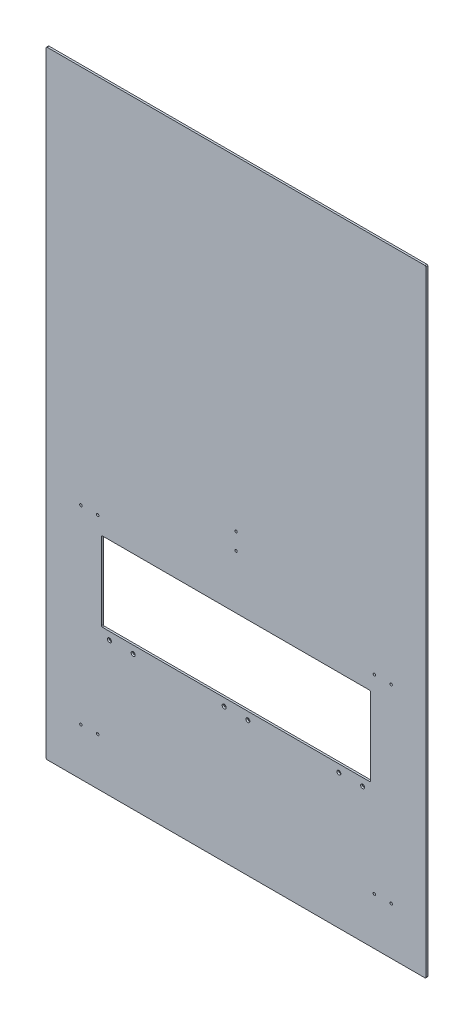
from build123d import *

# Parameters (mm, degrees)
SKETCH1_W                                     = 1219.2
SKETCH1_H                                     = 1981.2
SKETCH1_W_2                                   = 863.6
SKETCH1_H_2                                   = 254
BOSS_EXTRUDE1_DEPTH                           = 6.35
CSK_FOR_1_4_FLAT_HEAD_MACHINE_SCREW1_AT_COUNT = 2
CSK_FOR_1_4_FLAT_HEAD_MACHINE_SCREW1_AT_PITCH = 76.2
CSK_FOR_1_4_FLAT_HEAD_MACHINE_SCREW1_2_COUNT  = 2
CSK_FOR_1_4_FLAT_HEAD_MACHINE_SCREW1_2_PITCH  = 736.600036601
CSK_FOR_1_4_FLAT_HEAD_MACHINE_SCREW1_3_COUNT  = 2
CSK_FOR_1_4_FLAT_HEAD_MACHINE_SCREW1_3_PITCH  = 812.800033169
CSK_FOR_1_4_FLAT_HEAD_MACHINE_SCREW1_4_COUNT  = 2
CSK_FOR_1_4_FLAT_HEAD_MACHINE_SCREW1_4_PITCH  = 368.300013149
CSK_FOR_1_4_FLAT_HEAD_MACHINE_SCREW1_5_COUNT  = 2
CSK_FOR_1_4_FLAT_HEAD_MACHINE_SCREW1_5_PITCH  = 444.500010895
FILLET1_R                                     = 3.175
F_5_16_0_3125_DIAMETER_HOLE2_D                = 7.9375


with BuildPart() as part:
    # Sketch1 → Boss-Extrude1 (new body)
    with BuildSketch(Plane.XY):
        with Locations((609.6, 990.6)):
            Rectangle(SKETCH1_W, SKETCH1_H)
        with Locations((609.6, 584.2)):
            Rectangle(SKETCH1_W_2, SKETCH1_H_2, mode=Mode.SUBTRACT)
    extrude(amount=BOSS_EXTRUDE1_DEPTH)

    # Sketch3 → CSK for 1/4 Flat Head Machine Screw1 (revolve, cut)
    with BuildSketch(Plane(origin=(203.2, 432.304928843, 6.35), x_dir=(0, -1, 0), z_dir=(1, 0, 0))):
        Polygon((0, 0), (0, 6.35), (3.57124, 6.35), (3.57124, 3.298865467), (6.4389, 0), align=None)
    csk_for_1_4_flat_head_machine_screw1 = revolve(axis=Axis((203.2, 432.304928843, 12.7), (0, 0, -1)), mode=Mode.SUBTRACT)

    # CSK for 1/4 Flat Head Machine Screw1 at: CSK for 1/4 Flat Head Machine Screw1 ×2
    with Locations(*[(i * CSK_FOR_1_4_FLAT_HEAD_MACHINE_SCREW1_AT_PITCH, 0, 0) for i in range(1, CSK_FOR_1_4_FLAT_HEAD_MACHINE_SCREW1_AT_COUNT)]):
        add(csk_for_1_4_flat_head_machine_screw1, mode=Mode.SUBTRACT)

    # CSK for 1_4 Flat Head Machine Screw1 2: CSK for 1/4 Flat Head Machine Screw1 ×2
    with Locations(*[Vector(0.99999995, 0.000315241, 0) * (i * CSK_FOR_1_4_FLAT_HEAD_MACHINE_SCREW1_2_PITCH) for i in range(1, CSK_FOR_1_4_FLAT_HEAD_MACHINE_SCREW1_2_COUNT)]):
        add(csk_for_1_4_flat_head_machine_screw1, mode=Mode.SUBTRACT)

    # CSK for 1_4 Flat Head Machine Screw1 3: CSK for 1/4 Flat Head Machine Screw1 ×2
    with Locations(*[Vector(0.999999959, 0.000285687, 0) * (i * CSK_FOR_1_4_FLAT_HEAD_MACHINE_SCREW1_3_PITCH) for i in range(1, CSK_FOR_1_4_FLAT_HEAD_MACHINE_SCREW1_3_COUNT)]):
        add(csk_for_1_4_flat_head_machine_screw1, mode=Mode.SUBTRACT)

    # CSK for 1_4 Flat Head Machine Screw1 4: CSK for 1/4 Flat Head Machine Screw1 ×2
    with Locations(*[Vector(0.999999964, 0.000267211, 0) * (i * CSK_FOR_1_4_FLAT_HEAD_MACHINE_SCREW1_4_PITCH) for i in range(1, CSK_FOR_1_4_FLAT_HEAD_MACHINE_SCREW1_4_COUNT)]):
        add(csk_for_1_4_flat_head_machine_screw1, mode=Mode.SUBTRACT)

    # CSK for 1_4 Flat Head Machine Screw1 5: CSK for 1/4 Flat Head Machine Screw1 ×2
    with Locations(*[Vector(0.999999975, 0.000221404, 0) * (i * CSK_FOR_1_4_FLAT_HEAD_MACHINE_SCREW1_5_PITCH) for i in range(1, CSK_FOR_1_4_FLAT_HEAD_MACHINE_SCREW1_5_COUNT)]):
        add(csk_for_1_4_flat_head_machine_screw1, mode=Mode.SUBTRACT)

    # Fillet1
    fillet1_edges = [part.edges().sort_by_distance(p)[0] for p in [
        (177.8, 711.2, 3.175),
        (177.8, 457.2, 3.175),
        (1041.4, 457.2, 3.175),
        (1041.4, 711.2, 3.175),
        (0, 1981.2, 3.175),
        (1219.2, 1981.2, 3.175),
        (1219.2, 0, 3.175),
        (0, 0, 3.175),
    ]]
    fillet(fillet1_edges, radius=FILLET1_R)

    # 5/16 (0.3125) Diameter Hole2 (through all)
    with Locations(Plane.XY.offset(6.35)):
        with Locations((609.6, 938.2125), (111.5695, 762), (111.5695, 152.4), (165.5445, 152.4), (165.5445, 762), (1053.6555, 152.4), (1107.6305, 152.4), (1107.6305, 762), (1053.6555, 762), (609.6, 884.2375)):
            Hole(F_5_16_0_3125_DIAMETER_HOLE2_D / 2)


solid = part.part
